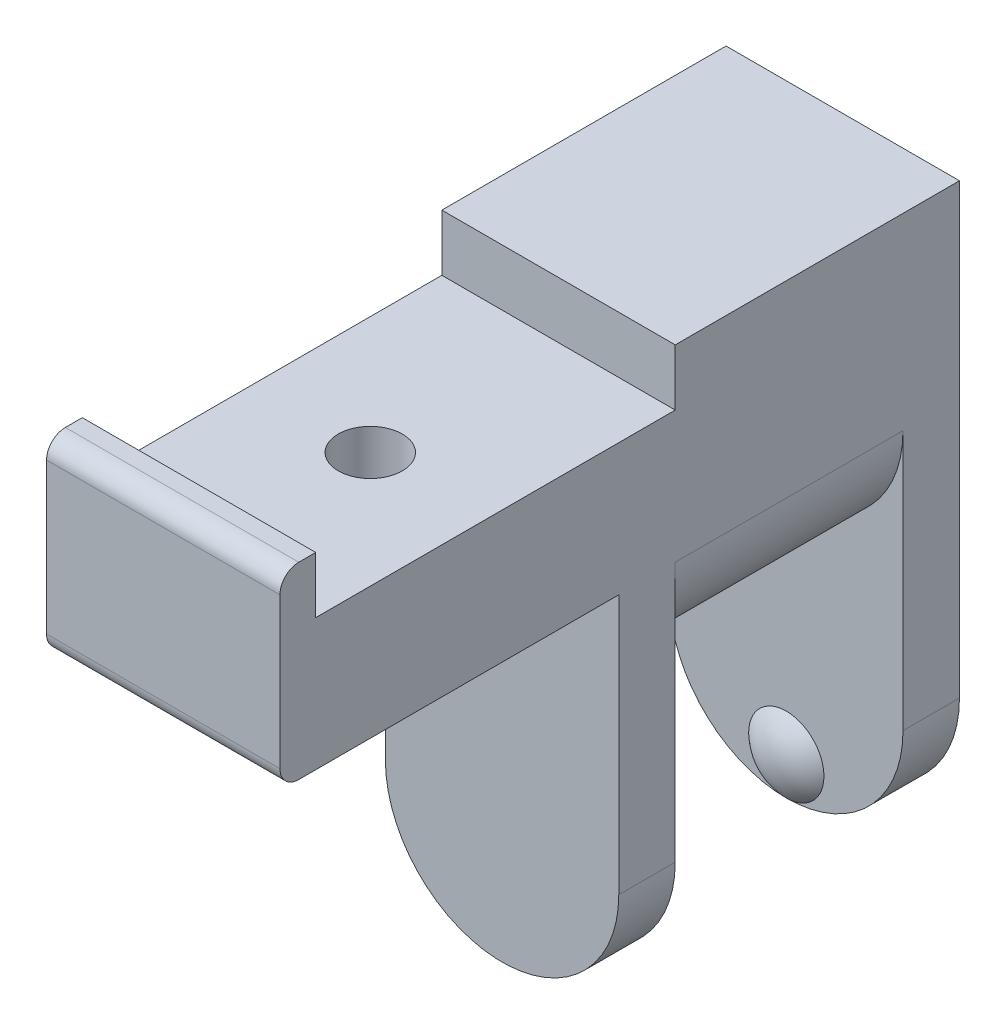
from build123d import *

# Parameters (mm, degrees)
SKETCH_2_W               = 12.1
SKETCH_2_H               = 8
EXTRUDE_1_DEPTH          = 12.4
CUT_EXTRUDE_1_DEPTH      = 12.1
CUT_EXTRUDE_2_DEPTH      = 22
CUT_EXTRUDE_2_DEPTH_BACK = 16.1
HOLE_WIZARD_M31_D        = 3.4
HOLE_WIZARD_M31_DEPTH    = 10
HOLE_WIZARD_M31_TIP      = 1.021463052
FILLET_1_R               = 1


with BuildPart() as part:
    # Эскиз2 → Бобышка-Вытянуть1 (new body)
    with BuildSketch(Plane(origin=(0, 0, 0), x_dir=(0, 0, -1), z_dir=(1, 0, 0))):
        Polygon((-19.1, 10), (-19.1, 7), (0, 7), (0, 10), (15.1, 10), (15.1, -20), (12.1, -20), (12.1, 0), (0, 0), (0, -20), (-3, -20), (-3, 0), (-21, 0), (-21, 10), align=None)
        with Locations((6.05, -4)):
            Rectangle(SKETCH_2_W, SKETCH_2_H)
    extrude(amount=EXTRUDE_1_DEPTH)

    # Эскиз3 → Вырез-Вытянуть1 (cut)
    with BuildSketch(Plane.XY):
        with BuildLine():
            Line((0, 0), (-4.310236897, 0))
            Line((-4.310236897, 0), (-4.310236897, -10.158248203))
            Line((-4.310236897, -10.158248203), (16.784307367, -10.158248203))
            Line((16.784307367, -10.158248203), (16.784307367, 0))
            Line((16.784307367, 0), (12.4, 0))
            ThreePointArc((12.4, 0), (6.2, -6.2), (0, 0))
        make_face()
    extrude(amount=-CUT_EXTRUDE_1_DEPTH, mode=Mode.SUBTRACT)

    # Эскиз4 → Вырез-Вытянуть2 (cut, two sides)
    with BuildSketch(Plane.XY) as cut_extrude_2_sk:
        with BuildLine():
            Line((0, -13.8), (-4.529189241, -13.8))
            Line((-4.529189241, -13.8), (-4.529189241, -23.032738442))
            Line((-4.529189241, -23.032738442), (17.457291493, -23.032738442))
            Line((17.457291493, -23.032738442), (17.457291493, -13.8))
            Line((17.457291493, -13.8), (12.4, -13.8))
            ThreePointArc((12.4, -13.8), (6.2, -20), (0, -13.8))
        make_face()
    extrude(amount=CUT_EXTRUDE_2_DEPTH, mode=Mode.SUBTRACT)
    extrude(cut_extrude_2_sk.sketch, amount=-CUT_EXTRUDE_2_DEPTH_BACK, mode=Mode.SUBTRACT)

    # Отверстие с зазором M31
    with Locations(Plane(origin=(0, 7, 0), x_dir=(1, 0, 0), z_dir=(0, 1, 0))):
        with Locations((6.25, -10.05)):
            Hole(HOLE_WIZARD_M31_D / 2, depth=HOLE_WIZARD_M31_DEPTH)
            with Locations((0, 0, -(HOLE_WIZARD_M31_DEPTH + HOLE_WIZARD_M31_TIP / 2))):  # 118° drill point
                Cone(0, HOLE_WIZARD_M31_D / 2, HOLE_WIZARD_M31_TIP, mode=Mode.SUBTRACT)

    # Скругление1
    fillet_1_edges = [part.edges().sort_by_distance(p)[0] for p in [
        (6.2, 0, 21),
        (6.2, 10, 21),
    ]]
    fillet(fillet_1_edges, radius=FILLET_1_R)

    # Эскиз9 → Повернуть1 (revolve)
    with BuildSketch(Plane(origin=(6.2, 0, 0), x_dir=(0, 0, -1), z_dir=(1, 0, 0))):
        with BuildLine():
            Line((12.1, -20), (12.1, -18))
            Line((12.1, -18), (11.3, -18))
            ThreePointArc((11.3, -18), (11.507417596, -19.077032961), (12.1, -20))
        make_face()
    revolve(axis=Axis((6.2, -18, -11.3), (0, 0, -1)))


solid = part.part
